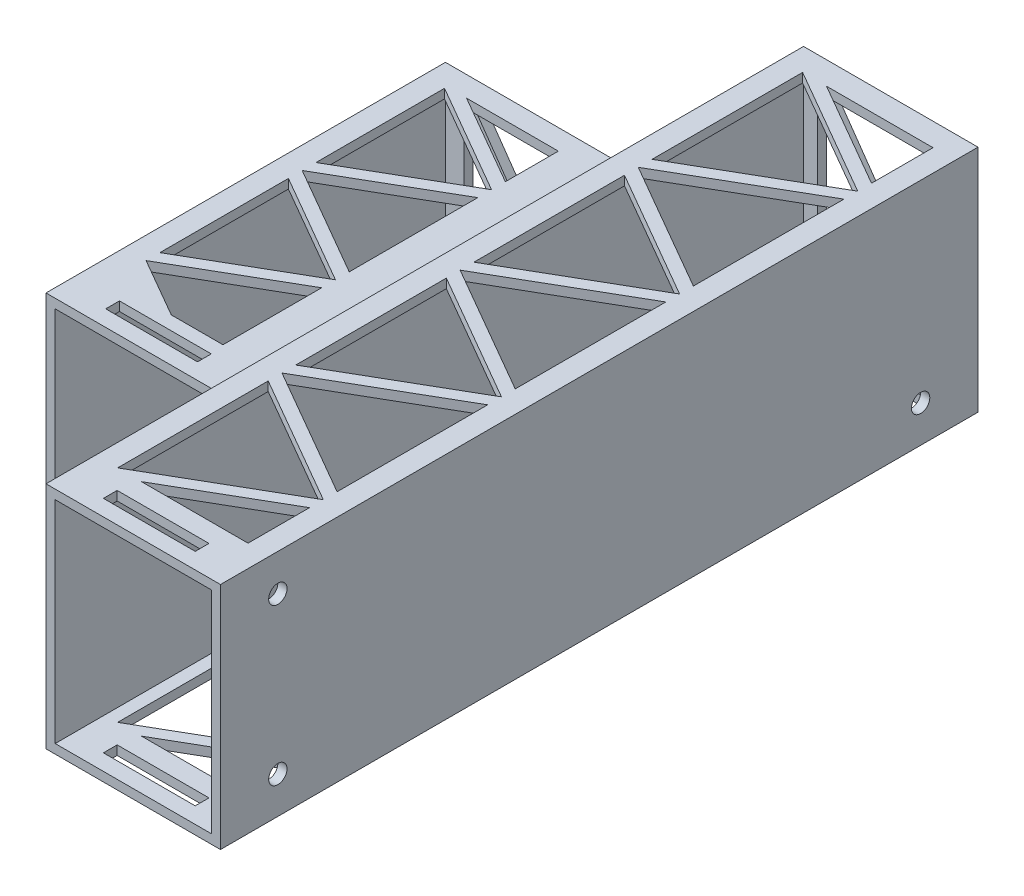
from build123d import *

# Parameters (mm, degrees)
BODYSKETCH_W              = 165
BODYSKETCH_H              = 50
BODY_DEPTH                = 38
HOLESKETCH_W              = 34
HOLESKETCH_H              = 46
HOLE_DEPTH                = 163
SECONDBATTERYSKETCH_W     = 87
SECONDBATTERYSKETCH_H     = 44
SECONDBATTERY_DEPTH       = 39
SECONDBATTERYHOLESKETCH_W = 37
SECONDBATTERYHOLESKETCH_H = 40
SECONDBATTERYHOLE_DEPTH   = 85
CONNECTORSKETCH_R         = 2
CUT_EXTRUDE3_DEPTH        = 15
STRAPSKETCH_W             = 20
STRAPSKETCH_H             = 3
CUT_EXTRUDE4_DEPTH        = 51
CUT_EXTRUDE5_DEPTH        = 51
CUT_EXTRUDE6_DEPTH        = 166


with BuildPart() as part:
    # BodySketch → Body (new body)
    with BuildSketch(Plane(origin=(0, 0, 0), x_dir=(0, 0, -1), z_dir=(1, 0, 0))):
        Rectangle(BODYSKETCH_W, BODYSKETCH_H)
    extrude(amount=BODY_DEPTH)

    # HoleSketch → Hole (cut)
    with BuildSketch(Plane.XY.offset(82.5)):
        with Locations((19, 0)):
            Rectangle(HOLESKETCH_W, HOLESKETCH_H)
    extrude(amount=-HOLE_DEPTH, mode=Mode.SUBTRACT)

    # SecondBatterySketch → SecondBattery (add)
    with BuildSketch(Plane.ZY):
        Rectangle(SECONDBATTERYSKETCH_W, SECONDBATTERYSKETCH_H)
    extrude(amount=SECONDBATTERY_DEPTH)

    # SecondBatteryHoleSketch → SecondBatteryHole (cut)
    with BuildSketch(Plane.XY.offset(43.5)):
        with Locations((-18.5, 0)):
            Rectangle(SECONDBATTERYHOLESKETCH_W, SECONDBATTERYHOLESKETCH_H)
    extrude(amount=-SECONDBATTERYHOLE_DEPTH, mode=Mode.SUBTRACT)

    # ConnectorSketch → Cut-Extrude3 (cut)
    with BuildSketch(Plane(origin=(38, 0, 0), x_dir=(0, 0, -1), z_dir=(1, 0, 0))):
        with Locations((-70, 17)):
            Circle(CONNECTORSKETCH_R)
        with Locations((-70, -17)):
            Circle(CONNECTORSKETCH_R)
        with Locations((70, -17)):
            Circle(CONNECTORSKETCH_R)
    extrude(amount=-CUT_EXTRUDE3_DEPTH, mode=Mode.SUBTRACT)

    # StrapSketch → Cut-Extrude4 (cut, through all)
    with BuildSketch(Plane(origin=(0, 25, 0), x_dir=(1, 0, 0), z_dir=(0, 1, 0))):
        with Locations((19, -77.5)):
            Rectangle(STRAPSKETCH_W, STRAPSKETCH_H)
        with Locations((-19.5, -38.5)):
            Rectangle(STRAPSKETCH_W, STRAPSKETCH_H)
    extrude(amount=-CUT_EXTRUDE4_DEPTH, mode=Mode.SUBTRACT)

    # WeightReduction → Cut-Extrude5 (cut, through all)
    with BuildSketch(Plane(origin=(0, 25, 0), x_dir=(1, 0, 0), z_dir=(0, 1, 0))):
        Polygon((4.8, 77.5), (4.8, 44.7), (33.205633244, 61.1), align=None)
        Polygon((33.205633244, -19.5), (33.205633244, -52.3), (4.8, -35.9), align=None)
        Polygon((33.205633244, 58.1), (33.205633244, 25.3), (4.8, 41.7), align=None)
        Polygon((4.8, 38.7), (4.8, 5.9), (33.205633244, 22.3), align=None)
        Polygon((33.205633244, 19.3), (33.205633244, -13.5), (4.8, 2.9), align=None)
        Polygon((4.8, -0.1), (4.8, -32.9), (33.205633244, -16.5), align=None)
        Polygon((4.8, -38.9), (4.8, -71.7), (33.205633244, -55.3), align=None)
        Polygon((33.205633244, -58.3), (33.205633244, -71.7), (9.996152423, -71.7), align=None)
        Polygon((33.205633244, 64.1), (33.205633244, 77.5), (9.996152423, 77.5), align=None)
        Polygon((-34.2, 38.5), (-34.2, 10.5), (-9.951288694, 24.5), align=None)
        Polygon((-9.951288694, 21.5), (-9.951288694, -6.5), (-34.2, 7.5), align=None)
        Polygon((-34.2, 4.5), (-34.2, -23.5), (-9.951288694, -9.5), align=None)
        Polygon((-34.2, -26.5), (-9.951288694, -12.5), (-9.951288694, -34), (-21.209618943, -34), align=None)
        Polygon((-9.951288694, 27.5), (-9.951288694, 39.047005384), (-29.951288694, 39.047005384), align=None)
    extrude(amount=-CUT_EXTRUDE5_DEPTH, mode=Mode.SUBTRACT)

    # weightCut → Cut-Extrude6 (cut, through all)
    with BuildSketch(Plane(origin=(0, 0, -82.5), x_dir=(-1, 0, 0), z_dir=(0, 0, -1))):
        Polygon((-31, -20), (-19, -2.862223919), (-7, -20), align=None)
        Polygon((-33, -18), (-20.396264312, 0), (-33, 18), align=None)
        Polygon((-31, 20), (-19, 2.862223919), (-7, 20), align=None)
        Polygon((-5, 18), (-17.603735688, 0), (-5, -18), align=None)
        Polygon((8, -19), (19.5, -2.576297922), (31, -19), align=None)
        Polygon((6, -17), (17.90352815, 0), (6, 17), align=None)
        Polygon((33, -17), (21.09647185, 0), (33, 17), align=None)
        Polygon((8, 19), (19.5, 2.576297922), (31, 19), align=None)
    extrude(amount=-CUT_EXTRUDE6_DEPTH, mode=Mode.SUBTRACT)


solid = part.part
